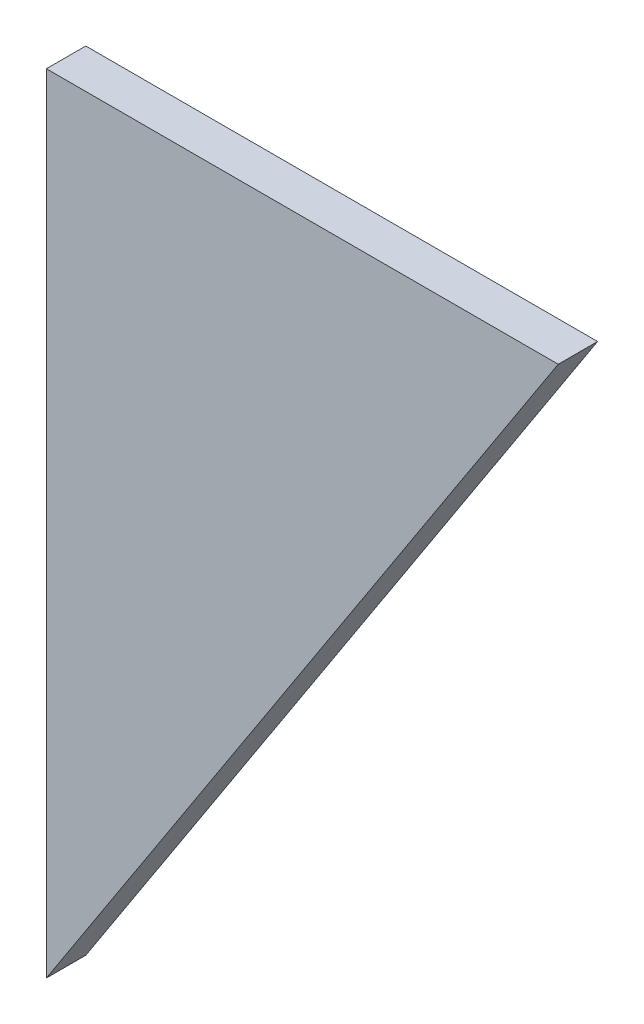
from build123d import *

# Parameters (mm, degrees)
BOSS_EXTRUDE1_DEPTH = 10


with BuildPart() as part:
    # Sketch1 → Boss-Extrude1 (new body)
    with BuildSketch(Plane.XY):
        Polygon((65, 100), (-65, 100), (-65, -100), align=None)
    extrude(amount=BOSS_EXTRUDE1_DEPTH)


solid = part.part
